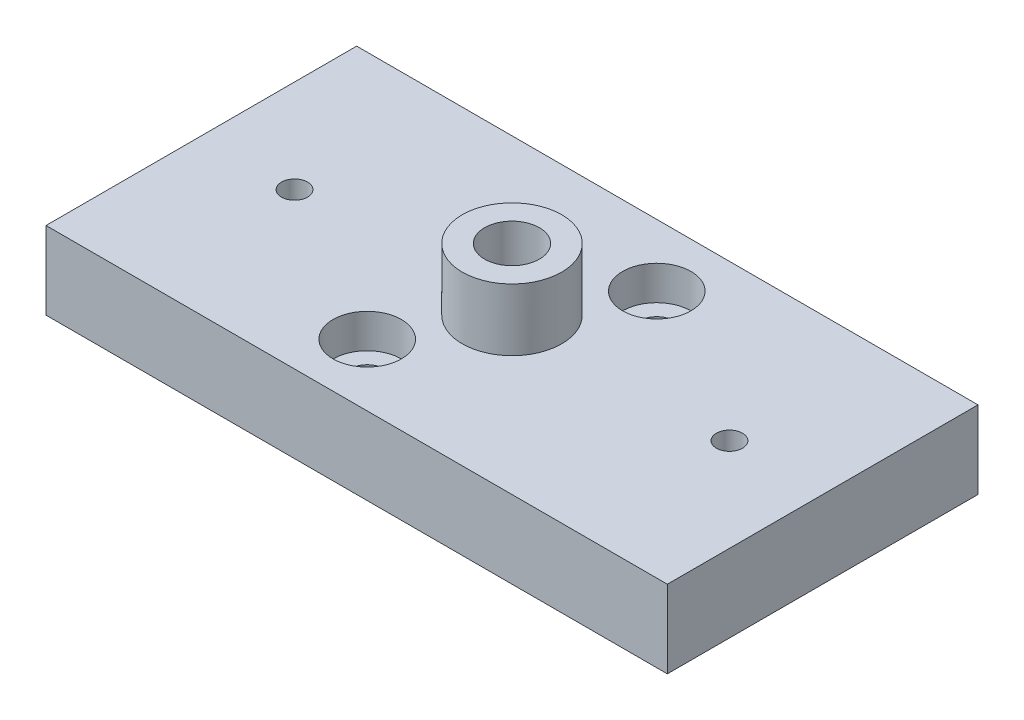
from build123d import *

# Parameters (mm, degrees)
SKETCH1_W                   = 100
SKETCH1_H                   = 50
BOSS_EXTRUDE1_DEPTH         = 12.5
SKETCH2_R                   = 8
BOSS_EXTRUDE2_DEPTH         = 10
M10X1_25_TAPPED_HOLE1_D     = 8.8
M10X1_25_TAPPED_HOLE1_DEPTH = 13
M10X1_25_TAPPED_HOLE1_TIP   = 2.643786724
M5_TAPPED_HOLE1_D           = 4.2
M5_TAPPED_HOLE1_DEPTH       = 10
M5_TAPPED_HOLE1_TIP         = 1.2618073
SKETCH8_R                   = 2.75
CUT_EXTRUDE1_DEPTH          = 23.5
SKETCH10_R                  = 5.5
CUT_EXTRUDE2_DEPTH          = 5.5


with BuildPart() as part:
    # Sketch1 → Boss-Extrude1 (new body)
    with BuildSketch(Plane(origin=(0, 0, 0), x_dir=(1, 0, 0), z_dir=(0, 1, 0))):
        Rectangle(SKETCH1_W, SKETCH1_H)
    extrude(amount=BOSS_EXTRUDE1_DEPTH)

    # Sketch2 → Boss-Extrude2 (add)
    with BuildSketch(Plane(origin=(0, 12.5, 0), x_dir=(1, 0, 0), z_dir=(0, 1, 0))):
        Circle(SKETCH2_R)
    extrude(amount=BOSS_EXTRUDE2_DEPTH)

    # M10x1.25 Tapped Hole1
    with Locations(Plane(origin=(0, 22.5, 0), x_dir=(1, 0, 0), z_dir=(0, 1, 0))):
        with Locations((0, 0)):
            Hole(M10X1_25_TAPPED_HOLE1_D / 2, depth=M10X1_25_TAPPED_HOLE1_DEPTH)
            with Locations((0, 0, -(M10X1_25_TAPPED_HOLE1_DEPTH + M10X1_25_TAPPED_HOLE1_TIP / 2))):  # 118° drill point
                Cone(0, M10X1_25_TAPPED_HOLE1_D / 2, M10X1_25_TAPPED_HOLE1_TIP, mode=Mode.SUBTRACT)

    # M5 Tapped Hole1
    with Locations(Plane(origin=(0, 12.5, 0), x_dir=(1, 0, 0), z_dir=(0, 1, 0))):
        with Locations((-35, 0), (35, 0)):
            Hole(M5_TAPPED_HOLE1_D / 2, depth=M5_TAPPED_HOLE1_DEPTH)
            with Locations((0, 0, -(M5_TAPPED_HOLE1_DEPTH + M5_TAPPED_HOLE1_TIP / 2))):  # 118° drill point
                Cone(0, M5_TAPPED_HOLE1_D / 2, M5_TAPPED_HOLE1_TIP, mode=Mode.SUBTRACT)

    # Sketch8 → Cut-Extrude1 (cut, through all)
    with BuildSketch(Plane.XZ):
        with Locations((8.3, -15)):
            Circle(SKETCH8_R)
        with Locations((-8.3, 15)):
            Circle(SKETCH8_R)
    extrude(amount=-CUT_EXTRUDE1_DEPTH, mode=Mode.SUBTRACT)

    # Sketch10 → Cut-Extrude2 (cut)
    with BuildSketch(Plane(origin=(0, 12.5, 0), x_dir=(1, 0, 0), z_dir=(0, 1, 0))):
        with Locations((8.3, 15)):
            Circle(SKETCH10_R)
        with Locations((-8.3, -15)):
            Circle(SKETCH10_R)
    extrude(amount=-CUT_EXTRUDE2_DEPTH, mode=Mode.SUBTRACT)


solid = part.part
